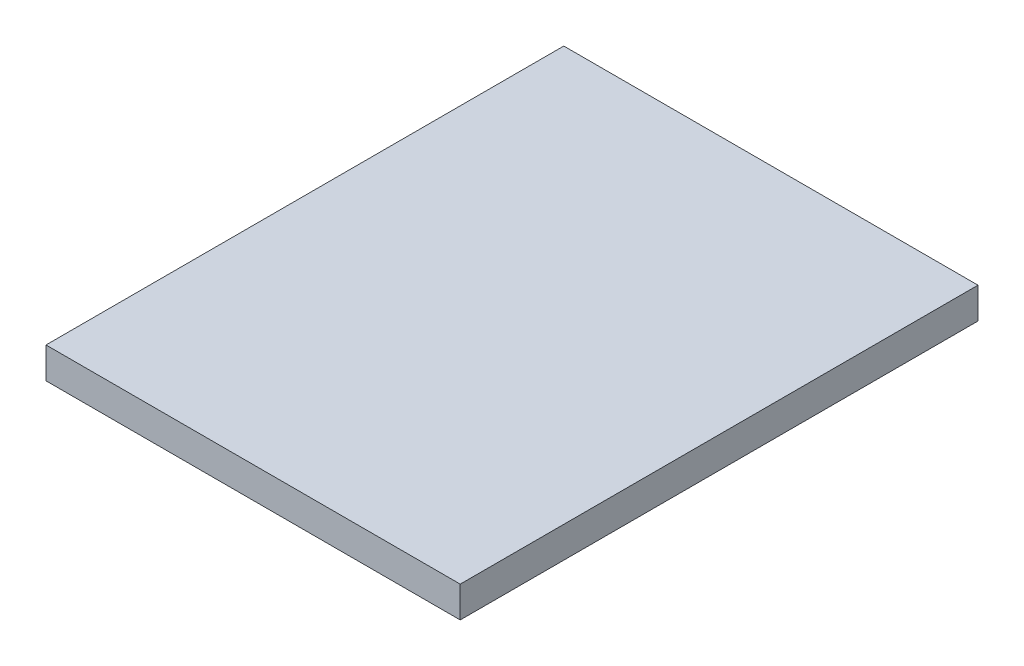
from build123d import *

# Parameters (mm, degrees)
SKETCH2_W           = 80
SKETCH2_H           = 100
BOSS_EXTRUDE1_DEPTH = 6


with BuildPart() as part:
    # Sketch2 → Boss-Extrude1 (new body)
    with BuildSketch(Plane(origin=(0, 0, 0), x_dir=(1, 0, 0), z_dir=(0, 1, 0))):
        with Locations((40, 50)):
            Rectangle(SKETCH2_W, SKETCH2_H)
    extrude(amount=BOSS_EXTRUDE1_DEPTH)


solid = part.part
